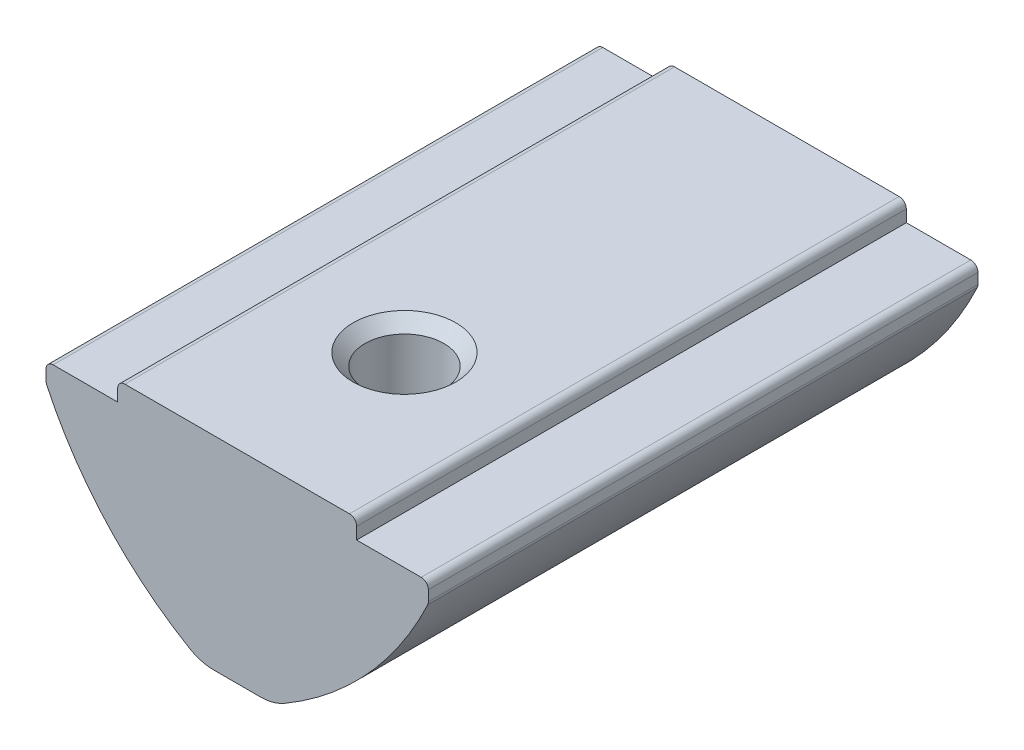
from build123d import *

# Parameters (mm, degrees)
EXTRUDE_1_DEPTH             = 11.5
FILLET_1_R                  = 0.3
FILLET_2_R                  = 2
HOLE_WIZARD_M42_D           = 3.3
HOLE_WIZARD_M42_CSINK_D     = 4.3
HOLE_WIZARD_M42_CSINK_ANGLE = 90


with BuildPart() as part:
    # Эскиз1 → Бобышка-Вытянуть1 (new body, symmetric)
    with BuildSketch(Plane.XY):
        with BuildLine():
            Line((-5, 0), (5, 0))
            Line((5, 0), (5, -0.8))
            Line((5, -0.8), (8, -0.8))
            Line((8, -0.8), (8, -1.6))
            ThreePointArc((8, -1.6), (5.309398779, -5.576969864), (1.5, -8.5))
            Line((1.5, -8.5), (-1.5, -8.5))
            ThreePointArc((-1.5, -8.5), (-5.309398779, -5.576969864), (-8, -1.6))
            Line((-8, -1.6), (-8, -0.8))
            Line((-8, -0.8), (-5, -0.8))
            Line((-5, -0.8), (-5, 0))
        make_face()
    extrude(amount=EXTRUDE_1_DEPTH, both=True)

    # Скругление1
    fillet_1_edges = [part.edges().sort_by_distance(p)[0] for p in [
        (8, -0.8, 0),
        (8, -1.6, 0),
        (-8, -1.6, 0),
        (-8, -0.8, 0),
        (-5, 0, 0),
        (5, 0, 0),
    ]]
    fillet(fillet_1_edges, radius=FILLET_1_R)

    # Скругление2
    fillet_2_edges = [part.edges().sort_by_distance(p)[0] for p in [
        (1.5, -8.5, 0),
        (-1.5, -8.5, 0),
    ]]
    fillet(fillet_2_edges, radius=FILLET_2_R)

    # Отверстие обработанное метчиком M42 (through all)
    with Locations(Plane(origin=(0, 0, 0), x_dir=(1, 0, 0), z_dir=(0, 1, 0))):
        with Locations((0, -4.5)):
            CounterSinkHole(HOLE_WIZARD_M42_D / 2, HOLE_WIZARD_M42_CSINK_D / 2, counter_sink_angle=HOLE_WIZARD_M42_CSINK_ANGLE)

    # Эскиз5 → Повернуть1 (revolve)
    with BuildSketch(Plane(origin=(0, 0, 0), x_dir=(0, 0, -1), z_dir=(1, 0, 0))):
        with BuildLine():
            Line((6.5, -4.3), (6.5, -9.3))
            ThreePointArc((6.5, -9.3), (4, -6.8), (6.5, -4.3))
        make_face()
    revolve(axis=Axis((0, -4.3, -6.5), (0, -1, 0)))


solid = part.part
